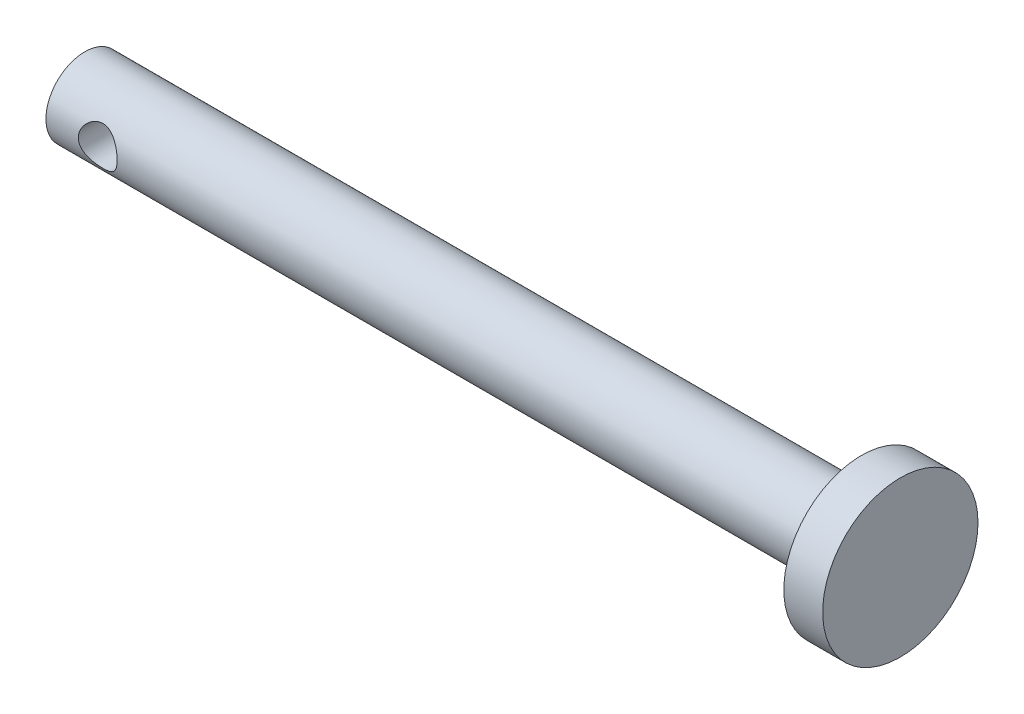
from build123d import *

# Parameters (mm, degrees)
SKETCH1_R               = 3
BOSS_EXTRUDE1_DEPTH     = 60
SKETCH2_R               = 6
BOSS_EXTRUDE2_DEPTH     = 3
SKETCH3_R               = 1.5
CUT_EXTRUDE1_DEPTH      = 7
CUT_EXTRUDE1_DEPTH_BACK = 7


with BuildPart() as part:
    # Sketch1 → Boss-Extrude1 (new body)
    with BuildSketch(Plane(origin=(0, 0, 0), x_dir=(0, 0, -1), z_dir=(1, 0, 0))):
        Circle(SKETCH1_R)
    extrude(amount=BOSS_EXTRUDE1_DEPTH)

    # Sketch2 → Boss-Extrude2 (add)
    with BuildSketch(Plane(origin=(60, 0, 0), x_dir=(0, 0, -1), z_dir=(1, 0, 0))):
        Circle(SKETCH2_R)
    extrude(amount=BOSS_EXTRUDE2_DEPTH)

    # Sketch3 → Cut-Extrude1 (cut, two sides)
    with BuildSketch(Plane.XY) as cut_extrude1_sk:
        with Locations((4, 0)):
            Circle(SKETCH3_R)
    extrude(amount=CUT_EXTRUDE1_DEPTH, mode=Mode.SUBTRACT)
    extrude(cut_extrude1_sk.sketch, amount=-CUT_EXTRUDE1_DEPTH_BACK, mode=Mode.SUBTRACT)


solid = part.part
